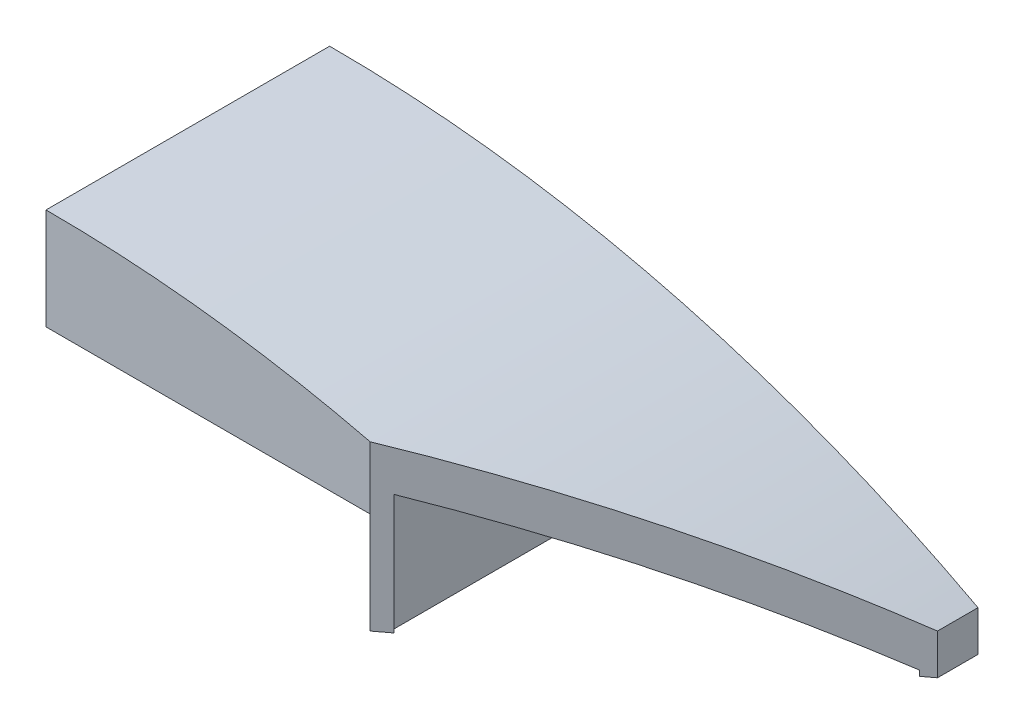
from build123d import *

# Parameters (mm, degrees)
BOSS_EXTRUDE1_DEPTH     = 4.445
CUT_EXTRUDE1_REACH      = 13.535
CUT_EXTRUDE1_END_RADIUS = 41.91
SKETCH2_W               = 9.8425
SKETCH2_H               = 8.255
CUT_EXTRUDE3_REACH      = 14.779
CUT_EXTRUDE3_END_RADIUS = 43.18
SKETCH3_W               = 9.525
SKETCH3_H               = 8.255
CUT_EXTRUDE5_DEPTH      = 12.535347849
CUT_EXTRUDE5_DEPTH_BACK = 12.535347849


with BuildPart() as part:
    # Sketch1 → Boss-Extrude1 (new, symmetric)
    with BuildSketch(Plane.XY):
        with BuildLine():
            Line((-10.16, 0), (-10.16, 3.175))
            ThreePointArc((-10.16, 3.175), (0.312688289, 1.885753156), (10.16, -1.905))
            Line((10.16, -1.905), (10.16, -3.175))
            Line((10.16, -3.175), (0, -3.175))
            Line((0, -3.175), (0, 0))
            Line((0, 0), (-10.16, 0))
        make_face()
    extrude(amount=BOSS_EXTRUDE1_DEPTH, both=True)

    # Cut-Extrude1: up to this cylinder (the profile starts inside it)
    cut_extrude1_end = Plane(origin=(-10.16, -40.005, 0), z_dir=(0, 0, -1)) * Cylinder(CUT_EXTRUDE1_END_RADIUS, 111.89, mode=Mode.PRIVATE)
    # Sketch2 → Cut-Extrude1 (cut, up to the surface)
    with BuildSketch(Plane.XZ, mode=Mode.PRIVATE) as cut_extrude1_sk1:
        with Locations((-4.92125, 0)):
            Rectangle(SKETCH2_W, SKETCH2_H)
    cut_extrude1_tool1 = extrude(cut_extrude1_sk1.sketch, amount=-CUT_EXTRUDE1_REACH, mode=Mode.PRIVATE) & cut_extrude1_end
    add(cut_extrude1_tool1.solids().sort_by_distance((-4.92125, 0, 0))[0], mode=Mode.SUBTRACT)

    # Cut-Extrude3: up to this cylinder (the profile starts inside it)
    cut_extrude3_end = Plane(origin=(-10.16, -41.275, 0), z_dir=(0, 0, -1)) * Cylinder(CUT_EXTRUDE3_END_RADIUS, 116.918, mode=Mode.PRIVATE)
    # Sketch3 → Cut-Extrude3 (cut, up to the surface)
    with BuildSketch(Plane.XZ.offset(3.175), mode=Mode.PRIVATE) as cut_extrude3_sk1:
        with Locations((5.08, 0)):
            Rectangle(SKETCH3_W, SKETCH3_H)
    cut_extrude3_tool1 = extrude(cut_extrude3_sk1.sketch, amount=-CUT_EXTRUDE3_REACH, mode=Mode.PRIVATE) & cut_extrude3_end
    add(cut_extrude3_tool1.solids().sort_by_distance((5.08, -3.175, 0))[0], mode=Mode.SUBTRACT)

    # Sketch7 → Cut-Extrude5 (cut, two sides)
    with BuildSketch(Plane(origin=(0, 0, 0), x_dir=(1, 0, 0), z_dir=(0, 1, 0))) as cut_extrude5_sk:
        Polygon((10.16, 3.175), (0, -4.445), (10.16, -4.445), align=None)
    extrude(amount=CUT_EXTRUDE5_DEPTH, mode=Mode.SUBTRACT)
    extrude(cut_extrude5_sk.sketch, amount=-CUT_EXTRUDE5_DEPTH_BACK, mode=Mode.SUBTRACT)


solid = part.part
